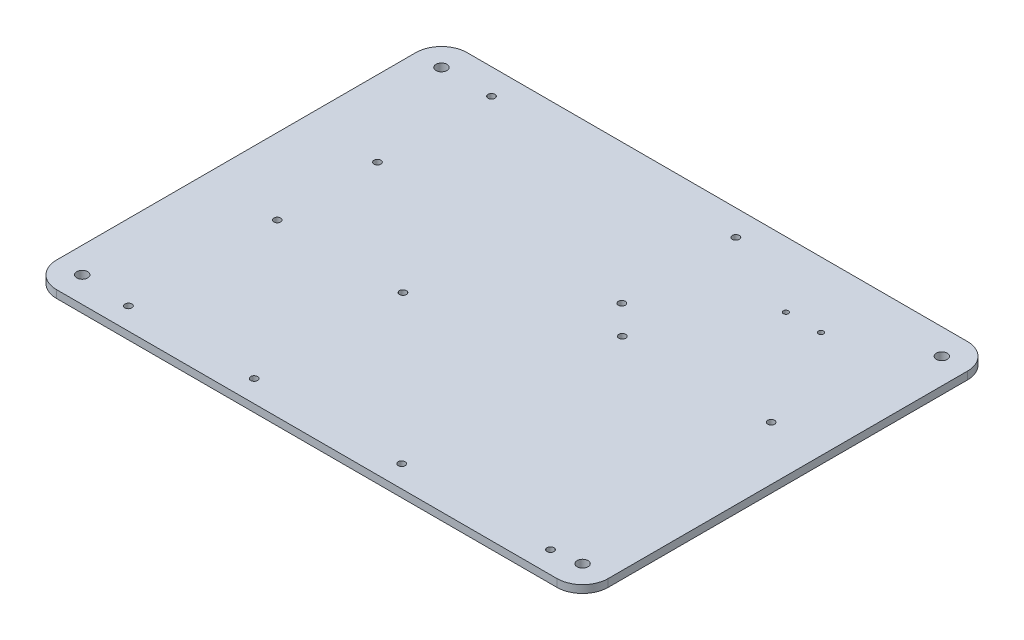
from build123d import *

# Parameters (mm, degrees)
SKETCH1_W           = 215
SKETCH1_H           = 160
BOSS_EXTRUDE1_DEPTH = 3
SKETCH2_R           = 1.35
SKETCH2_R_2         = 1
SKETCH2_R_3         = 2.125
CUT_EXTRUDE1_DEPTH  = 4
FILLET1_R           = 10


with BuildPart() as part:
    # Sketch1 → Boss-Extrude1 (new body)
    with BuildSketch(Plane(origin=(0, 210, 0), x_dir=(1, 0, 0), z_dir=(0, 1, 0))):
        Rectangle(SKETCH1_W, SKETCH1_H)
    extrude(amount=BOSS_EXTRUDE1_DEPTH)

    # Sketch2 → Cut-Extrude1 (cut, through all)
    with BuildSketch(Plane(origin=(0, 213, 0), x_dir=(1, 0, 0), z_dir=(0, 1, 0))):
        with Locations((-78, -13.5)):
            Circle(SKETCH2_R)
        with Locations((-29, -13.5)):
            Circle(SKETCH2_R)
        with Locations((-29, -71.5)):
            Circle(SKETCH2_R)
        with Locations((-78, -71.5)):
            Circle(SKETCH2_R)
        with Locations((86.5, 14.5)):
            Circle(SKETCH2_R)
        with Locations((86.5, -71.5)):
            Circle(SKETCH2_R)
        with Locations((28.5, -71.5)):
            Circle(SKETCH2_R)
        with Locations((28.5, 14.5)):
            Circle(SKETCH2_R)
        with Locations((-78, 70)):
            Circle(SKETCH2_R)
        with Locations((-78, 25.55)):
            Circle(SKETCH2_R)
        with Locations((17.25, 25.55)):
            Circle(SKETCH2_R)
        with Locations((17.25, 70)):
            Circle(SKETCH2_R)
        with Locations((52.25, 54.5)):
            Circle(SKETCH2_R_2)
        with Locations((65.95, 54.5)):
            Circle(SKETCH2_R_2)
        with Locations((97.5, -70)):
            Circle(SKETCH2_R_3)
        with Locations((97.5, 70)):
            Circle(SKETCH2_R_3)
        with Locations((-97.5, 70)):
            Circle(SKETCH2_R_3)
        with Locations((-97.5, -70)):
            Circle(SKETCH2_R_3)
    extrude(amount=-CUT_EXTRUDE1_DEPTH, mode=Mode.SUBTRACT)

    # Fillet1
    fillet1_edges = [part.edges().sort_by_distance(p)[0] for p in [
        (-107.5, 211.5, -80),
        (107.5, 211.5, -80),
        (107.5, 211.5, 80),
        (-107.5, 211.5, 80),
    ]]
    fillet(fillet1_edges, radius=FILLET1_R)


solid = part.part
